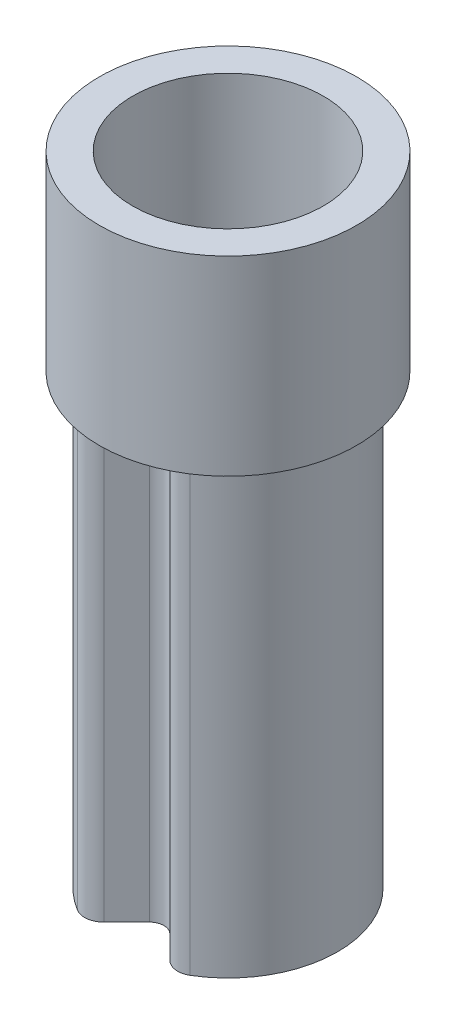
from build123d import *

# Parameters (mm, degrees)
BOSS_EXTRUDE1_DEPTH = 4.7
FILLET1_R           = 0.05
FILLET2_R           = 0.2
SKETCH2_R           = 1.35
SKETCH2_R_2         = 1
BOSS_EXTRUDE2_DEPTH = 2


with BuildPart() as part:
    # Sketch1 → Boss-Extrude1 (new body)
    with BuildSketch(Plane(origin=(0, 0, 0), x_dir=(1, 0, 0), z_dir=(0, 1, 0))):
        with BuildLine():
            Line((-0.448807004, -1.058807004), (-0.106066017, -0.716066017))
            ThreePointArc((-0.106066017, -0.716066017), (0, -0.672132034), (0.106066017, -0.716066017))
            Line((0.106066017, -0.716066017), (0.448807004, -1.058807004))
            ThreePointArc((0.448807004, -1.058807004), (0, 1.15), (-0.448807004, -1.058807004))
        make_face()
        with BuildLine():
            Line((-0.479612457, -0.877480422), (-0.212132034, -0.61))
            ThreePointArc((-0.212132034, -0.61), (0, -0.522132034), (0.212132034, -0.61))
            Line((0.212132034, -0.61), (0.479612457, -0.877480422))
            ThreePointArc((0.479612457, -0.877480422), (0, 1), (-0.479612457, -0.877480422))
        make_face(mode=Mode.SUBTRACT)
    extrude(amount=BOSS_EXTRUDE1_DEPTH)

    # Fillet1
    fillet1_edges = [part.edges().sort_by_distance(p)[0] for p in [
        (0.479612457, 2.35, 0.877480422),
        (-0.479612457, 2.35, 0.877480422),
    ]]
    fillet(fillet1_edges, radius=FILLET1_R)

    # Fillet2
    fillet2_edges = [part.edges().sort_by_distance(p)[0] for p in [
        (-0.448807004, 2.35, 1.058807004),
        (0.448807004, 2.35, 1.058807004),
    ]]
    fillet(fillet2_edges, radius=FILLET2_R)

    # Sketch2 → Boss-Extrude2 (add)
    with BuildSketch(Plane(origin=(0, 4.7, 0), x_dir=(1, 0, 0), z_dir=(0, 1, 0))):
        Circle(SKETCH2_R)
        Circle(SKETCH2_R_2, mode=Mode.SUBTRACT)
    extrude(amount=BOSS_EXTRUDE2_DEPTH)


solid = part.part
